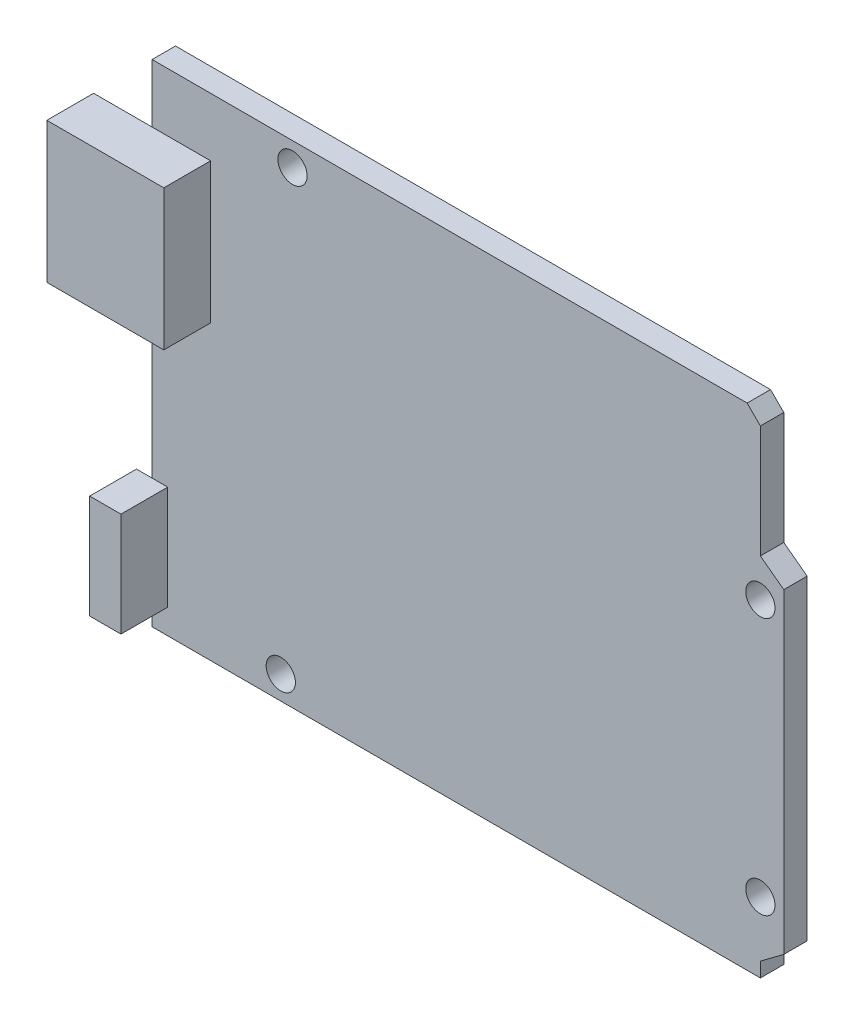
from build123d import *

# Parameters (mm, degrees)
SKETCH1_W           = 68.58
SKETCH1_H           = 53.34
BOSS_EXTRUDE1_DEPTH = 2.54
SKETCH2_W           = 12.7
SKETCH2_H           = 15.24
SKETCH2_W_2         = 3.39503639
SKETCH2_H_2         = 11.2855496
BOSS_EXTRUDE2_DEPTH = 5.08
SKETCH3_R           = 1.5875
CUT_EXTRUDE1_DEPTH  = 10.16
CUT_EXTRUDE2_DEPTH  = 3.54


with BuildPart() as part:
    # Sketch1 → Boss-Extrude1 (new body)
    with BuildSketch(Plane.XY):
        Rectangle(SKETCH1_W, SKETCH1_H)
    extrude(amount=BOSS_EXTRUDE1_DEPTH)

    # Sketch2 → Boss-Extrude2 (add)
    with BuildSketch(Plane.XY.offset(2.54)):
        with Locations((-34.29, 12.7)):
            Rectangle(SKETCH2_W, SKETCH2_H)
        with Locations((-34.29, -18.328779787)):
            Rectangle(SKETCH2_W_2, SKETCH2_H_2)
    extrude(amount=BOSS_EXTRUDE2_DEPTH)

    # Sketch3 → Cut-Extrude1 (cut)
    with BuildSketch(Plane.XY.offset(2.54)):
        with Locations((-19.05, 24.13)):
            Circle(SKETCH3_R)
        with Locations((-20.32, -24.13)):
            Circle(SKETCH3_R)
        with Locations((31.75, 8.89)):
            Circle(SKETCH3_R)
        with Locations((31.75, -19.05)):
            Circle(SKETCH3_R)
    extrude(amount=-CUT_EXTRUDE1_DEPTH, mode=Mode.SUBTRACT)

    # Sketch4 → Cut-Extrude2 (cut, through all)
    with BuildSketch(Plane.XY.offset(2.54)):
        Polygon((30.313159021, 26.67), (31.75, 25.233159021), (31.75, 13.012702255), (34.29, 11.115796447), (34.29, 26.67), align=None)
        Polygon((34.29, -23.181547096), (31.75, -25.078452904), (31.75, -26.67), (34.29, -26.67), align=None)
    extrude(amount=-CUT_EXTRUDE2_DEPTH, mode=Mode.SUBTRACT)


solid = part.part
